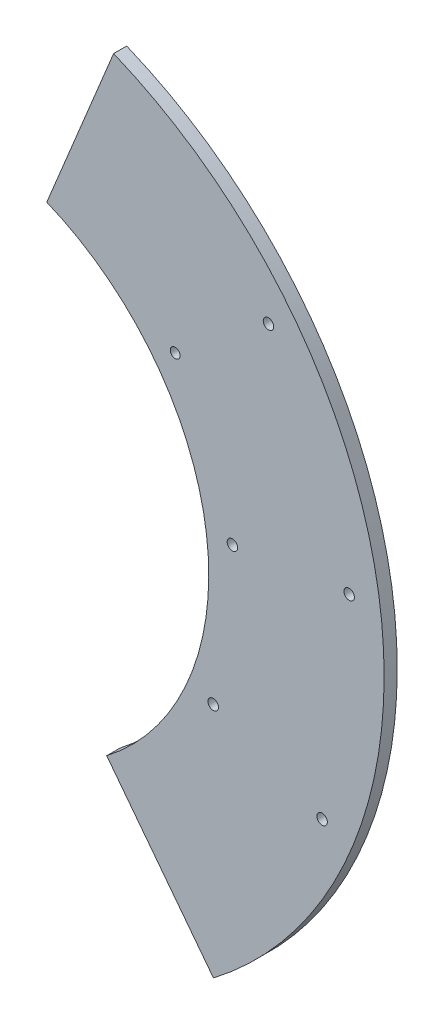
from build123d import *

# Parameters (mm, degrees)
BOSS_EXTRU_2_DEPTH      = 5
ENL_V_MAT_EXTRU_1_DEPTH = 10
ESQUISSE3_W             = 70.825033907
ESQUISSE3_H             = 52.172348309
ENL_V_MAT_EXTRU_2_DEPTH = 10
ESQUISSE4_R             = 2
ESQUISSE4_R_2           = 1.87013138
ENL_V_MAT_EXTRU_3_DEPTH = 10
ENL_V_MAT_EXTRU_4_DEPTH = 10


with BuildPart() as part:
    # Esquisse1 → Boss.-Extru.2 (new body)
    with BuildSketch(Plane.XY):
        with BuildLine():
            Line((-2, 166.988023523), (-2, 99.979998))
            ThreePointArc((-2, 99.979998), (100, 0), (-2, -99.979998))
            Line((-2, -99.979998), (-2, -166.988023523))
            ThreePointArc((-2, -166.988023523), (167, 0), (-2, 166.988023523))
        make_face()
    extrude(amount=BOSS_EXTRU_2_DEPTH)

    # Esquisse2 → Enlèv. mat.-Extru.1 (cut)
    with BuildSketch(Plane.XY.offset(5)):
        Polygon((29.390638032, 43.425593165), (38.112910781, 92.452182407), (63.648561005, 154.395144619), (68.028776979, 172.275239399), (-24.955464007, 192.914301625), (-14.988060504, 82.801476905), align=None)
        Polygon((56.192163409, 19.645406226), (29.390638032, 43.425593165), (-11.148286352, -184.437631398), (102.415881909, -156.025065414), (102.415881909, -133.007210905), (53.907034164, -84.226074749), align=None)
    extrude(amount=-ENL_V_MAT_EXTRU_1_DEPTH, mode=Mode.SUBTRACT)

    # Esquisse3 → Enlèv. mat.-Extru.2 (cut)
    with BuildSketch(Plane.XY.offset(5)):
        with Locations((-10.008332903, -121.270932698)):
            Rectangle(ESQUISSE3_W, ESQUISSE3_H)
    extrude(amount=-ENL_V_MAT_EXTRU_2_DEPTH, mode=Mode.SUBTRACT)

    # Esquisse4 → Enlèv. mat.-Extru.3 (cut)
    with BuildSketch(Plane.XY.offset(5)):
        with Locations((109.034633389, 14.54127648)):
            Circle(ESQUISSE4_R)
        with Locations((101.697400647, -41.92420186)):
            Circle(ESQUISSE4_R)
        with Locations((87.156124167, 67.11043153)):
            Circle(ESQUISSE4_R_2)
        with Locations((122.810902236, 94.564698974)):
            Circle(ESQUISSE4_R)
        with Locations((143.30088273, -59.075011711)):
            Circle(ESQUISSE4_R)
        with Locations((153.639710685, 20.489980494)):
            Circle(ESQUISSE4_R)
    extrude(amount=-ENL_V_MAT_EXTRU_3_DEPTH, mode=Mode.SUBTRACT)

    # Esquisse5 → Enlèv. mat.-Extru.4 (cut)
    with BuildSketch(Plane.XY.offset(5)):
        Polygon((61.009483209, -79.232840152), (101.798321541, -132.386184065), (46.643469874, -98.897205978), (43.215654561, -74.196784885), (51.84018638, -72.999910462), align=None)
    extrude(amount=-ENL_V_MAT_EXTRU_4_DEPTH, mode=Mode.SUBTRACT)


solid = part.part
